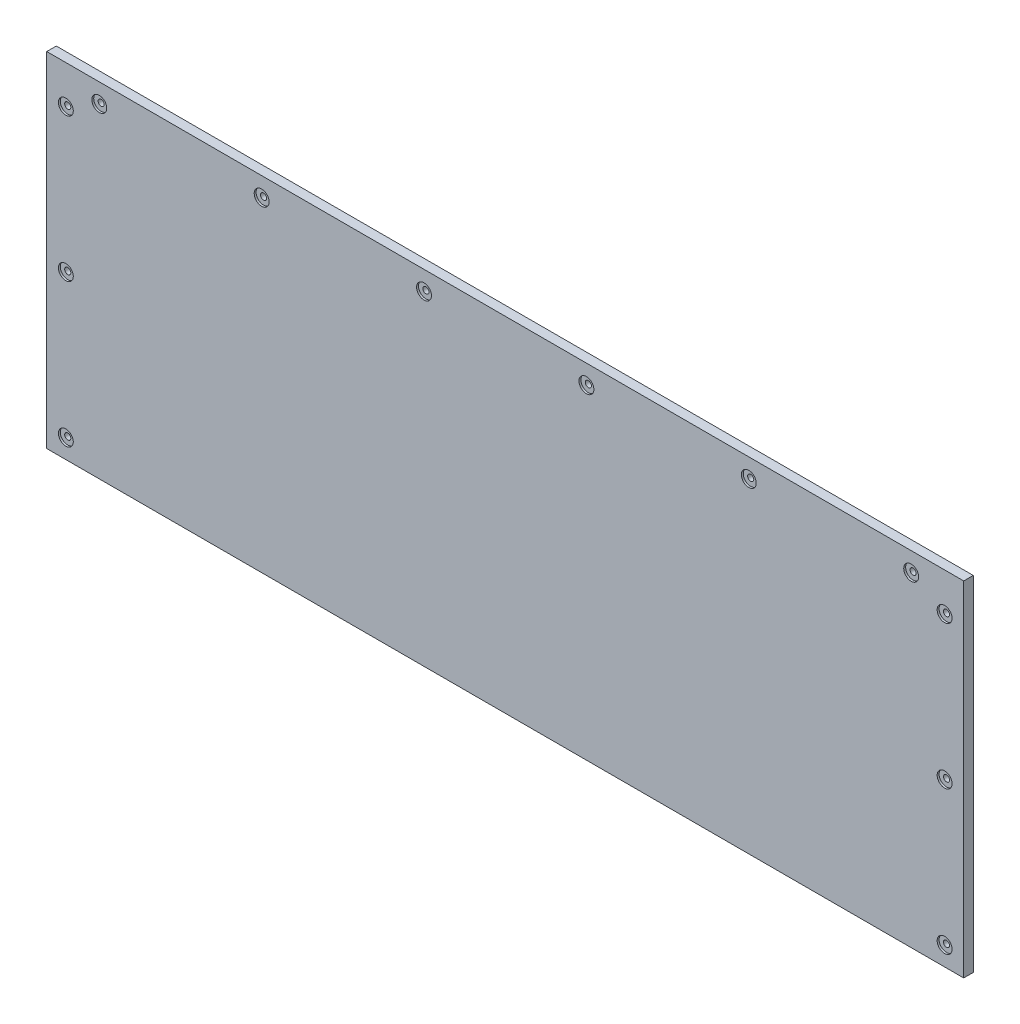
from build123d import *

# Parameters (mm, degrees)
SKETCH1_W           = 609.6
SKETCH1_H           = 228.6
BOSS_EXTRUDE1_DEPTH = 6.35
SKETCH2_R           = 2.032
CUT_EXTRUDE4_DEPTH  = 7.35
SKETCH3_R           = 4.953
CUT_EXTRUDE6_DEPTH  = 1.27
SKETCH4_R           = 2.032
CUT_EXTRUDE7_DEPTH  = 7.35
SKETCH5_R           = 4.953
CUT_EXTRUDE8_DEPTH  = 1.27


with BuildPart() as part:
    # Sketch1 → Boss-Extrude1 (new body)
    with BuildSketch(Plane.XY):
        with Locations((304.8, 114.3)):
            Rectangle(SKETCH1_W, SKETCH1_H)
    extrude(amount=BOSS_EXTRUDE1_DEPTH)

    # Sketch2 → Cut-Extrude4 (cut, through all)
    with BuildSketch(Plane.XY.offset(6.35)):
        with Locations((12.7, 203.2)):
            Circle(SKETCH2_R)
        with Locations((12.7, 107.95)):
            Circle(SKETCH2_R)
        with Locations((12.7, 12.7)):
            Circle(SKETCH2_R)
        with Locations((596.9, 12.7)):
            Circle(SKETCH2_R)
        with Locations((596.9, 107.95)):
            Circle(SKETCH2_R)
        with Locations((596.9, 203.2)):
            Circle(SKETCH2_R)
    extrude(amount=-CUT_EXTRUDE4_DEPTH, mode=Mode.SUBTRACT)

    # Sketch3 → Cut-Extrude6 (cut)
    with BuildSketch(Plane.XY.offset(6.35)):
        with Locations((12.7, 203.2)):
            Circle(SKETCH3_R)
        with Locations((12.7, 107.95)):
            Circle(SKETCH3_R)
        with Locations((12.7, 12.7)):
            Circle(SKETCH3_R)
        with Locations((596.9, 12.7)):
            Circle(SKETCH3_R)
        with Locations((596.9, 107.95)):
            Circle(SKETCH3_R)
        with Locations((596.9, 203.2)):
            Circle(SKETCH3_R)
    extrude(amount=-CUT_EXTRUDE6_DEPTH, mode=Mode.SUBTRACT)

    # Sketch4 → Cut-Extrude7 (cut, through all)
    with BuildSketch(Plane.XY.offset(6.35)):
        with Locations((34.925, 215.9)):
            Circle(SKETCH4_R)
        with Locations((142.875, 215.9)):
            Circle(SKETCH4_R)
        with Locations((250.825, 215.9)):
            Circle(SKETCH4_R)
        with Locations((358.775, 215.9)):
            Circle(SKETCH4_R)
        with Locations((466.725, 215.9)):
            Circle(SKETCH4_R)
        with Locations((574.675, 215.9)):
            Circle(SKETCH4_R)
    extrude(amount=-CUT_EXTRUDE7_DEPTH, mode=Mode.SUBTRACT)

    # Sketch5 → Cut-Extrude8 (cut)
    with BuildSketch(Plane.XY.offset(6.35)):
        with Locations((34.925, 215.9)):
            Circle(SKETCH5_R)
        with Locations((142.875, 215.9)):
            Circle(SKETCH5_R)
        with Locations((250.825, 215.9)):
            Circle(SKETCH5_R)
        with Locations((358.775, 215.9)):
            Circle(SKETCH5_R)
        with Locations((466.725, 215.9)):
            Circle(SKETCH5_R)
        with Locations((574.675, 215.9)):
            Circle(SKETCH5_R)
    extrude(amount=-CUT_EXTRUDE8_DEPTH, mode=Mode.SUBTRACT)


solid = part.part
